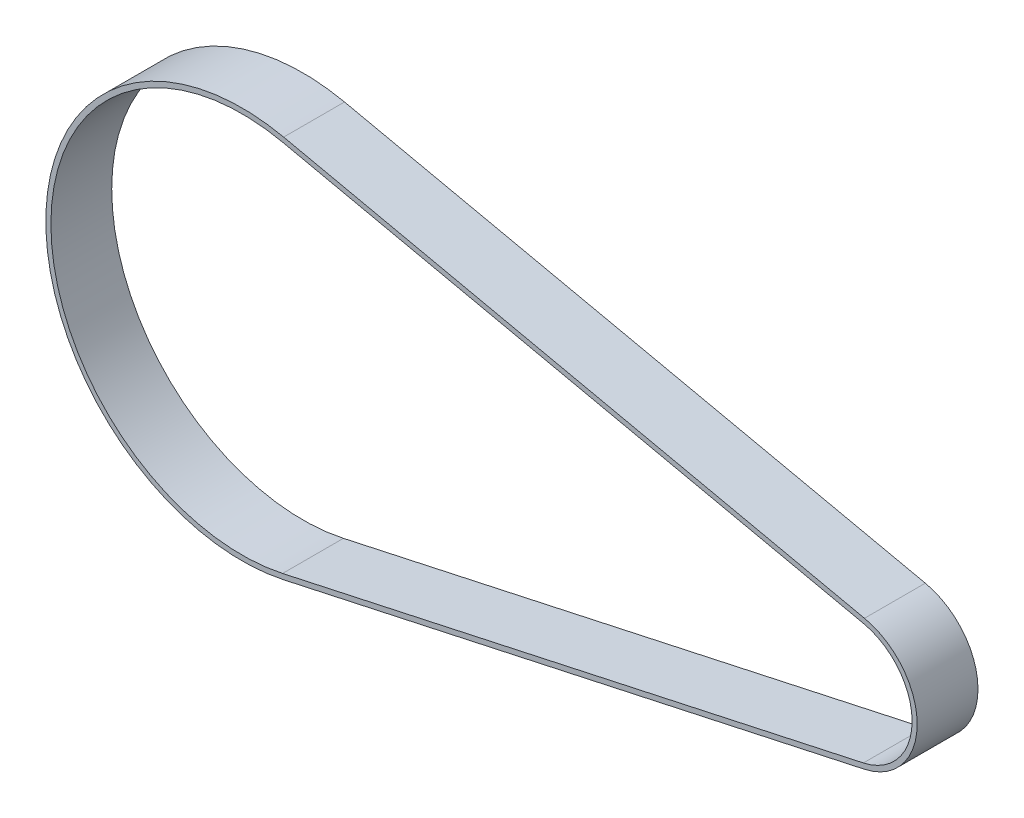
from build123d import *

# Parameters (mm, degrees)
SALIENTE_EXTRUIR1_DEPTH = 6


with BuildPart() as part:
    # Croquis1 → Saliente-Extruir1 (new body)
    with BuildSketch(Plane.XY):
        with BuildLine():
            Line((61.4025, -6.449263039), (4.111875, -18.908066638))
            ThreePointArc((4.111875, -18.908066638), (-19.35, 0), (4.111875, 18.908066638))
            Line((4.111875, 18.908066638), (61.4025, 6.449263039))
            ThreePointArc((61.4025, 6.449263039), (66.6, 0), (61.4025, -6.449263039))
        make_face()
        with BuildLine():
            Line((4.005625, 18.419486105), (61.29625, 5.960682506))
            ThreePointArc((61.29625, 5.960682506), (66.1, 0), (61.29625, -5.960682506))
            Line((61.29625, -5.960682506), (4.005625, -18.419486105))
            ThreePointArc((4.005625, -18.419486105), (-18.85, 0), (4.005625, 18.419486105))
        make_face(mode=Mode.SUBTRACT)
    extrude(amount=SALIENTE_EXTRUIR1_DEPTH)


solid = part.part
